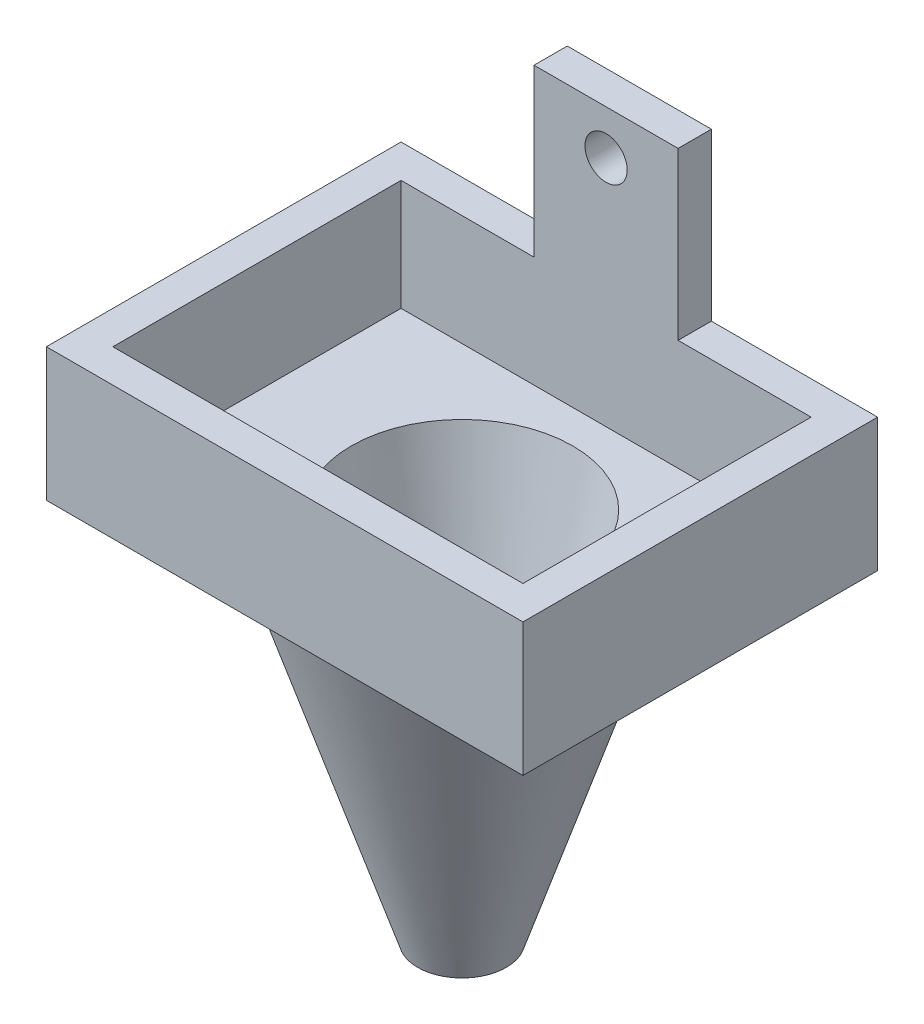
from build123d import *

# Parameters (mm, degrees)
SKETCH1_W           = 43
SKETCH1_H           = 32
SKETCH1_W_2         = 37
SKETCH1_H_2         = 26
BOSS_EXTRUDE1_DEPTH = 10
SKETCH2_W           = 13
SKETCH2_H           = 3
BOSS_EXTRUDE2_DEPTH = 15
CUT_EXTRUDE1_REACH  = 59
SKETCH3_R           = 1.905
SKETCH4_W           = 43
SKETCH4_H           = 32
BOSS_EXTRUDE3_DEPTH = 2
CUT_EXTRUDE2_REACH  = 58.303
SKETCH5_R           = 10
BOSS_EXTRUDE4_START = -5
SKETCH14_R          = 2.75
BOSS_EXTRUDE4_DEPTH = 25
SKETCH16_R          = 1.75
CUT_EXTRUDE3_DEPTH  = 30
SKETCH17_R          = 2.5
CUT_EXTRUDE4_DEPTH  = 10


with BuildPart() as part:
    # Sketch1 → Boss-Extrude1 (new body)
    with BuildSketch(Plane(origin=(0, 0, 0), x_dir=(1, 0, 0), z_dir=(0, 1, 0))):
        with Locations((18.5, 13)):
            Rectangle(SKETCH1_W, SKETCH1_H)
        with Locations((18.5, 13)):
            Rectangle(SKETCH1_W_2, SKETCH1_H_2, mode=Mode.SUBTRACT)
    extrude(amount=BOSS_EXTRUDE1_DEPTH)

    # Sketch2 → Boss-Extrude2 (add)
    with BuildSketch(Plane(origin=(0, 10, 0), x_dir=(1, 0, 0), z_dir=(0, 1, 0))):
        with Locations((18.5, 27.5)):
            Rectangle(SKETCH2_W, SKETCH2_H)
    extrude(amount=BOSS_EXTRUDE2_DEPTH)

    # Sketch3 → Cut-Extrude1 (cut, up to next)
    with BuildSketch(Plane(origin=(0, 0, -29), x_dir=(-1, 0, 0), z_dir=(0, 0, -1)), mode=Mode.PRIVATE) as cut_extrude1_sk1:
        with Locations((-18.5, 21)):
            Circle(SKETCH3_R)
    cut_extrude1_tool1 = extrude(cut_extrude1_sk1.sketch, amount=-CUT_EXTRUDE1_REACH, mode=Mode.PRIVATE) & part.part
    add(cut_extrude1_tool1.solids().sort_by_distance((18.5, 21, -29))[0], mode=Mode.SUBTRACT)

    # Sketch4 → Boss-Extrude3 (add)
    with BuildSketch(Plane.XZ):
        with Locations((18.5, -13)):
            Rectangle(SKETCH4_W, SKETCH4_H)
    extrude(amount=BOSS_EXTRUDE3_DEPTH)

    # Sketch5 → Cut-Extrude2 (cut, up to next)
    with BuildSketch(Plane.XZ.offset(2), mode=Mode.PRIVATE) as cut_extrude2_sk1:
        with Locations((18.5, -13)):
            Circle(SKETCH5_R)
    cut_extrude2_tool1 = extrude(cut_extrude2_sk1.sketch, amount=-CUT_EXTRUDE2_REACH, mode=Mode.PRIVATE) & part.part
    add(cut_extrude2_tool1.solids().sort_by_distance((18.5, -2, -13))[0], mode=Mode.SUBTRACT)

    # Sketch9 → Revolve1 (revolve)
    with BuildSketch(Plane.XY.offset(-13)):
        Polygon((28.5, 0), (21.5, -33.75), (22.5, -33.75), (33.5, 0), align=None)
    revolve(axis=Axis((18.5, -2, -13), (0, -1, 0)))

    # Sketch14 → Boss-Extrude4 (add)
    with BuildSketch(Plane(origin=(18.5, -13.221888935, -28.050276014), x_dir=(-1, 0, 0), z_dir=(0, -0.7846028557301679, 0.619998676434124)).offset(BOSS_EXTRUDE4_START)):
        with Locations((0.305660396, 0)):
            Circle(SKETCH14_R)
    extrude(amount=BOSS_EXTRUDE4_DEPTH)

    # Sketch16 → Cut-Extrude3 (cut)
    with BuildSketch(Plane(origin=(0, 9.428731153, -7.45064945), x_dir=(1, 0, 0), z_dir=(0, 0.7846028557301677, -0.619998676434124))):
        with Locations((18.194339604, 30.205880304)):
            Circle(SKETCH16_R)
    extrude(amount=-CUT_EXTRUDE3_DEPTH, mode=Mode.SUBTRACT)

    # Sketch17 → Cut-Extrude4 (cut)
    with BuildSketch(Plane.XZ.offset(33.75)):
        with Locations((18.5, -13)):
            Circle(SKETCH17_R)
    extrude(amount=-CUT_EXTRUDE4_DEPTH, mode=Mode.SUBTRACT)


solid = part.part
